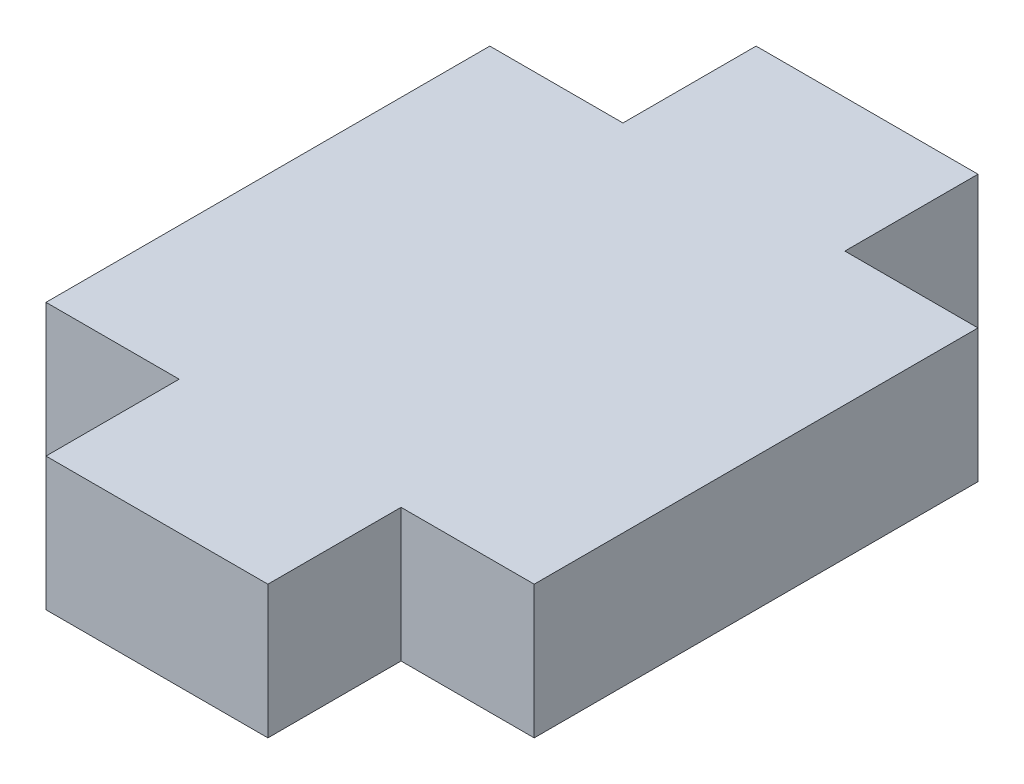
from build123d import *

# Parameters (mm, degrees)
BOSS_EXTRUDE1_DEPTH = 1.5


with BuildPart() as part:
    # Sketch1 → Boss-Extrude1 (new body, symmetric)
    with BuildSketch(Plane(origin=(0, 0, 0), x_dir=(1, 0, 0), z_dir=(0, 1, 0))):
        Polygon((-5.5, 5), (-5.5, -5), (-2.5, -5), (-2.5, -8), (2.5, -8), (2.5, -5), (5.5, -5), (5.5, 5), (2.5, 5), (2.5, 8), (-2.5, 8), (-2.5, 5), align=None)
    extrude(amount=BOSS_EXTRUDE1_DEPTH, both=True)


solid = part.part
